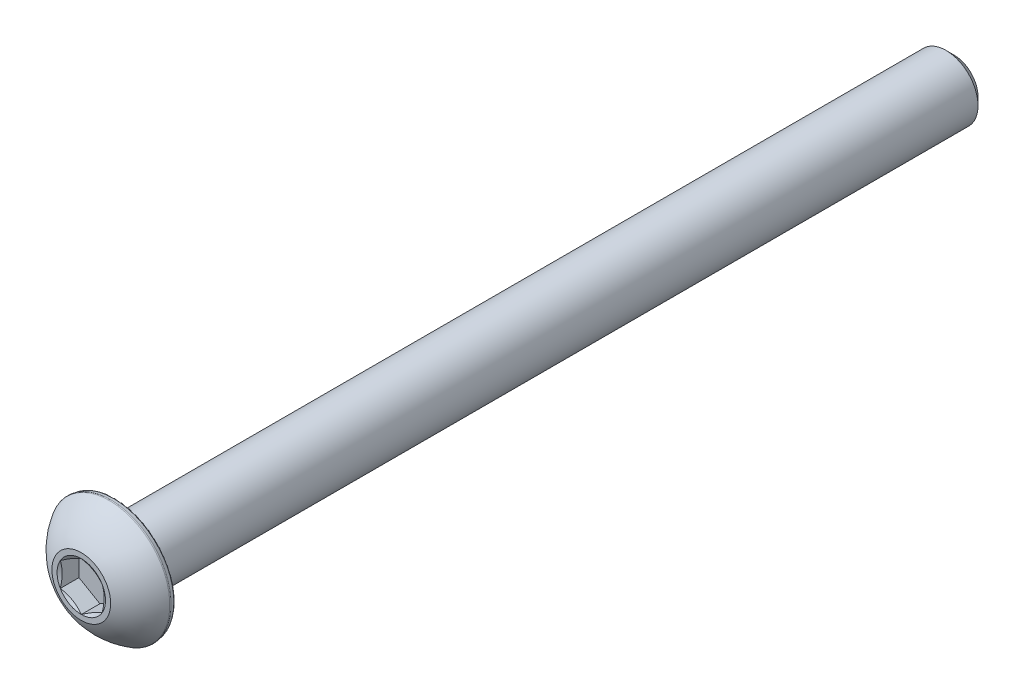
from build123d import *

# Parameters (mm, degrees)
CUT_EXTRUDE1_DEPTH = 1.41097
SKETCH5_R          = 1.833087105
CUT_EXTRUDE2_DEPTH = 1.41097
CUT_EXTRUDE2_DRAFT = -60
FILLET1_R          = 0.12827


with BuildPart() as part:
    # Sketch3 → Revolve1 (revolve)
    with BuildSketch(Plane(origin=(0, 0, 0), x_dir=(0, 0, -1), z_dir=(1, 0, 0))):
        with BuildLine():
            Line((-33.0327, 0), (-33.0327, 2.2225))
            ThreePointArc((-33.0327, 2.2225), (-32.12696038, 3.573966445), (-30.85211, 4.5847))
            Line((-30.85211, 4.5847), (-30.4673, 4.516847615))
            Line((-30.4673, 4.516847615), (-30.4673, 2.413))
            Line((-30.4673, 2.413), (32.4373875, 2.413))
            Line((32.4373875, 2.413), (33.0327, 1.8176875))
            Line((33.0327, 1.8176875), (33.0327, 0))
            Line((33.0327, 0), (-33.0327, 0))
        make_face()
    revolve(axis=Axis((0, 0, 33.0327), (0, 0, -1)))

    # Sketch4 → Cut-Extrude1 (cut)
    with BuildSketch(Plane.XY.offset(33.0327)):
        Polygon((-1.5875, -0.916543552), (0, -1.833087105), (1.5875, -0.916543552), (1.5875, 0.916543552), (0, 1.833087105), (-1.5875, 0.916543552), align=None)
    extrude(amount=-CUT_EXTRUDE1_DEPTH, mode=Mode.SUBTRACT)


with BuildPart() as cut_extrude2_tool:
    # Sketch5 → Cut-Extrude2 (with draft: the straight prism first)
    with BuildSketch(Plane.XY.offset(33.0327)):
        Circle(SKETCH5_R)
    extrude(amount=-CUT_EXTRUDE2_DEPTH)
    # Cut-Extrude2: the draft: its side faces are tilted about the plane it starts from
    cut_extrude2_sides = [cut_extrude2_tool.faces().sort_by_distance(p)[0] for p in [
        (-1.833087105, 0, 32.327215),
    ]]
    draft(cut_extrude2_sides, Plane.XY.offset(33.0327), CUT_EXTRUDE2_DRAFT)


with BuildPart() as part_1:
    add(part.part)

    # Cut-Extrude2: cut by cut_extrude2_tool
    add(cut_extrude2_tool.part, mode=Mode.SUBTRACT)

    # Fillet1
    fillet1_edges = [part_1.edges().sort_by_distance(p)[0] for p in [
        (0, -4.516847615, 30.4673),
        (0, -4.5847, 30.85211),
    ]]
    fillet(fillet1_edges, radius=FILLET1_R)


solid = part_1.part
